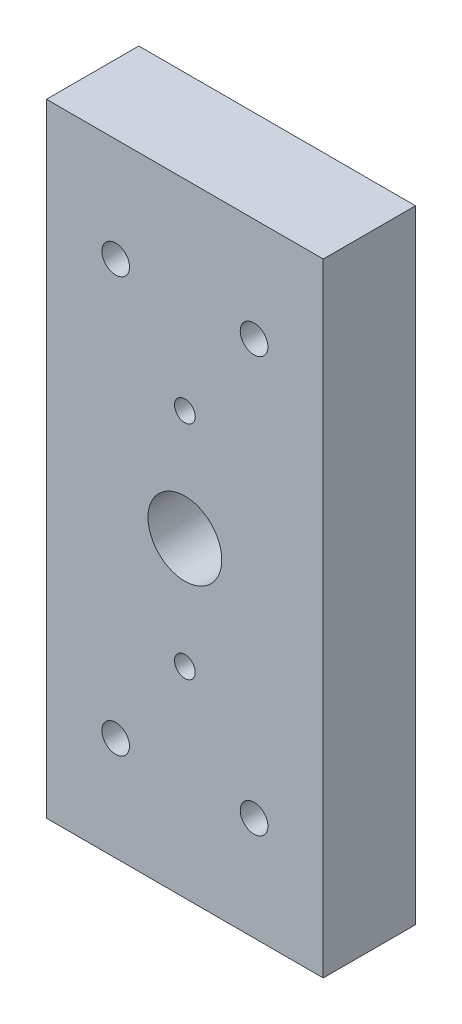
from build123d import *

# Parameters (mm, degrees)
SKETCH1_R          = 3
SKETCH1_R_2        = 2.25
EXTRUDE1_DEPTH     = 20
SKETCH2_R          = 5
CUT_EXTRUDE1_DEPTH = 6
SKETCH3_R          = 8
CUT_EXTRUDE2_DEPTH = 20
SKETCH4_W          = 10
SKETCH4_H          = 135
EXTRUDE2_DEPTH     = 20


with BuildPart() as part:
    # Sketch1 → Extrude1 (new body)
    with BuildSketch(Plane.XY):
        Polygon((5, 135), (0, 135), (-10, 135), (-10, 0), (0, 0), (40, 0), (50, 0), (50, 135), (40, 135), align=None)
        with Locations((5, 22.5)):
            Circle(SKETCH1_R, mode=Mode.SUBTRACT)
        with Locations((35, 22.5)):
            Circle(SKETCH1_R, mode=Mode.SUBTRACT)
        with Locations((20.000131027, 43.499934589)):
            Circle(SKETCH1_R_2, mode=Mode.SUBTRACT)
        with Locations((5, 112.5)):
            Circle(SKETCH1_R, mode=Mode.SUBTRACT)
        with Locations((20.000131027, 91.49994372)):
            Circle(SKETCH1_R_2, mode=Mode.SUBTRACT)
        with Locations((35, 112.5)):
            Circle(SKETCH1_R, mode=Mode.SUBTRACT)
    extrude(amount=EXTRUDE1_DEPTH)

    # Sketch2 → Cut-Extrude1 (cut)
    with BuildSketch(Plane(origin=(0, 0, 0), x_dir=(-1, 0, 0), z_dir=(0, 0, -1))):
        with Locations((-35, 112.5)):
            Circle(SKETCH2_R)
        with Locations((-5, 112.5)):
            Circle(SKETCH2_R)
        with Locations((-35, 22.5)):
            Circle(SKETCH2_R)
        with Locations((-5, 22.5)):
            Circle(SKETCH2_R)
    extrude(amount=-CUT_EXTRUDE1_DEPTH, mode=Mode.SUBTRACT)

    # Sketch3 → Cut-Extrude2 (cut)
    with BuildSketch(Plane(origin=(0, 0, 0), x_dir=(-1, 0, 0), z_dir=(0, 0, -1))):
        with Locations((-20, 67.5)):
            Circle(SKETCH3_R)
    extrude(amount=-CUT_EXTRUDE2_DEPTH, mode=Mode.SUBTRACT)

    # Sketch4 → Extrude2 (add)
    with BuildSketch(Plane(origin=(0, 0, 0), x_dir=(-1, 0, 0), z_dir=(0, 0, -1))):
        with Locations((-45, 67.5)):
            Rectangle(SKETCH4_W, SKETCH4_H)
        with Locations((5, 67.5)):
            Rectangle(SKETCH4_W, SKETCH4_H)
    extrude(amount=-EXTRUDE2_DEPTH)


solid = part.part
